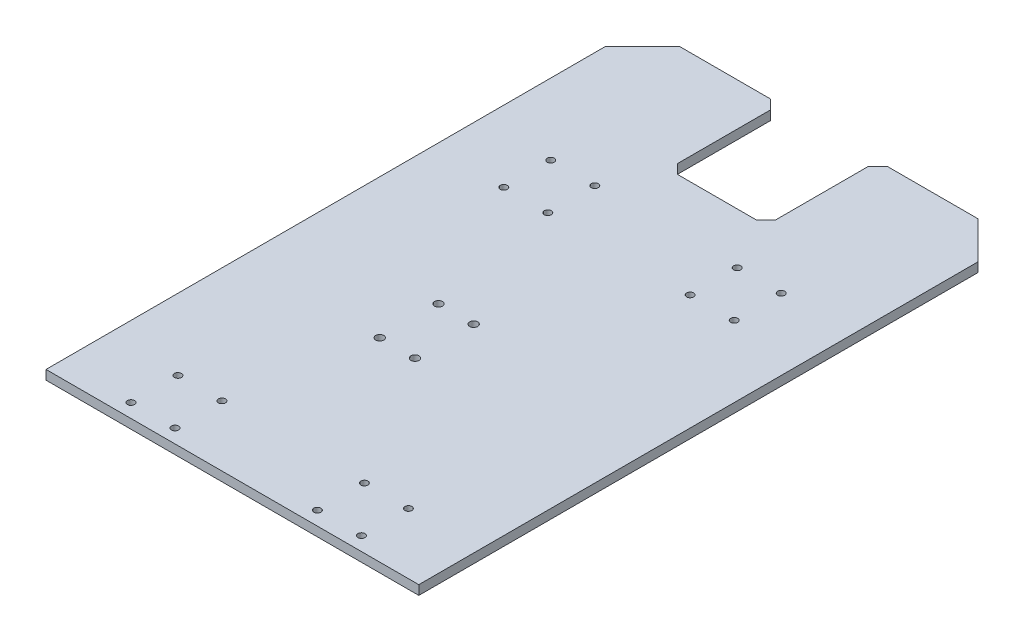
from build123d import *

# Parameters (mm, degrees)
SKETCH2_W                = 254
SKETCH2_H                = 304.8
BOSS_EXTRUDE1_DEPTH      = 6.35
M4_CLEARANCE_HOLE1_D     = 4.8
M4_CLEARANCE_HOLE1_DEPTH = 6.35
SKETCH6_W                = 254
SKETCH6_H                = 6.35
BOSS_EXTRUDE2_DEPTH      = 101.6
CHAMFER1_SIZE            = 25.4
SKETCH7_W                = 66.675
SKETCH7_H                = 76.2
CUT_EXTRUDE1_DEPTH       = 7.35
CHAMFER2_SIZE            = 6.35
M5_CLEARANCE_HOLE1_D     = 5.5


with BuildPart() as part:
    # Sketch2 → Boss-Extrude1 (new body)
    with BuildSketch(Plane(origin=(0, 0, 0), x_dir=(1, 0, 0), z_dir=(0, 1, 0))):
        Rectangle(SKETCH2_W, SKETCH2_H)
    extrude(amount=BOSS_EXTRUDE1_DEPTH)

    # M4 Clearance Hole1
    with Locations(Plane(origin=(0, 6.35, 0), x_dir=(1, 0, 0), z_dir=(0, 1, 0))):
        with Locations((78.5, -111), (48.5, -111), (48.5, -143), (78.5, -143), (-48.5, -111), (-48.5, -143), (-78.5, -111), (-78.5, -143), (78.5, 143), (78.5, 111), (48.5, 143), (48.5, 111), (-48.5, 143), (-48.5, 111), (-78.5, 143), (-78.5, 111)):
            Hole(M4_CLEARANCE_HOLE1_D / 2, depth=M4_CLEARANCE_HOLE1_DEPTH)

    # Sketch6 → Boss-Extrude2 (add)
    with BuildSketch(Plane(origin=(0, 0, -152.4), x_dir=(-1, 0, 0), z_dir=(0, 0, -1))):
        with Locations((0, 3.175)):
            Rectangle(SKETCH6_W, SKETCH6_H)
    extrude(amount=BOSS_EXTRUDE2_DEPTH)

    # Chamfer1
    chamfer1_edges = [part.edges().sort_by_distance(p)[0] for p in [
        (127, 3.175, -254),
        (-127, 3.175, -254),
    ]]
    chamfer(chamfer1_edges, length=CHAMFER1_SIZE)

    # Sketch7 → Cut-Extrude1 (cut, through all)
    with BuildSketch(Plane(origin=(0, 6.35, 0), x_dir=(1, 0, 0), z_dir=(0, 1, 0))):
        with Locations((0, 215.9)):
            Rectangle(SKETCH7_W, SKETCH7_H)
    extrude(amount=-CUT_EXTRUDE1_DEPTH, mode=Mode.SUBTRACT)

    # Chamfer2
    chamfer2_edges = [part.edges().sort_by_distance(p)[0] for p in [
        (33.3375, 3.175, -254),
        (33.3375, 3.175, -177.8),
        (-33.3375, 3.175, -177.8),
        (-33.3375, 3.175, -254),
    ]]
    chamfer(chamfer2_edges, length=CHAMFER2_SIZE)

    # M5 Clearance Hole1 (through all)
    with Locations(Plane(origin=(0, 6.35, 0), x_dir=(1, 0, 0), z_dir=(0, 1, 0))):
        with Locations((-8, -20.000000026), (-8, 19.999999974), (-32, 19.999999974), (-32, -20.000000026)):
            Hole(M5_CLEARANCE_HOLE1_D / 2)


solid = part.part
